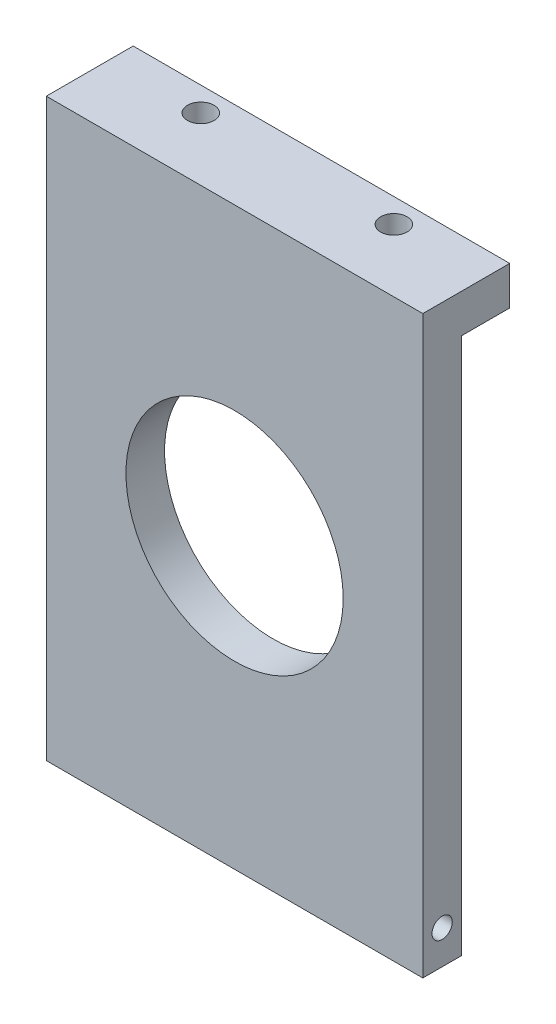
from build123d import *

# Parameters (mm, degrees)
SKETCH_1_W                  = 78
SKETCH_1_H                  = 119.63
SKETCH_1_R                  = 22.5
EXTRUDE_1_DEPTH             = 8
HOLE_WIZARD_M5_1_AT_2_COUNT = 2
HOLE_WIZARD_M5_1_AT_2_PITCH = 58
SKETCH_4_W                  = 78
SKETCH_4_H                  = 23.52391086
EXTRUDE_2_DEPTH             = 8
SKETCH_5_W                  = 78
SKETCH_5_H                  = 8.43
EXTRUDE_3_DEPTH             = 10
SKETCH_6_W                  = 78
SKETCH_6_H                  = 18
CUT_EXTRUDE_1_DEPTH         = 0.43
SKETCH_7_R                  = 2.75
CUT_EXTRUDE_2_DEPTH         = 9
HOLE_WIZARD_M5_2_AT_2_COUNT = 2
HOLE_WIZARD_M5_2_AT_2_PITCH = 90


with BuildPart() as part:
    # 草图1 → 凸台-拉伸1 (new body)
    with BuildSketch(Plane.XY):
        with Locations((-39, 59.815)):
            Rectangle(SKETCH_1_W, SKETCH_1_H)
        with Locations((-39, 59.815)):
            Circle(SKETCH_1_R, mode=Mode.SUBTRACT)
    extrude(amount=EXTRUDE_1_DEPTH)

    # 草图3 → M5 螺纹孔1 (revolve, cut)
    with BuildSketch(Plane(origin=(-68, 119.63, 4), x_dir=(0, 0, 1), z_dir=(1, 0, 0))):
        Polygon((0, 0), (0, 13.6618073), (2.1, 12.4), (2.1, 0), align=None)
    hole_wizard_m5_1 = revolve(axis=Axis((-68, 125.98, 4), (0, -1, 0)), mode=Mode.SUBTRACT)

    # M5 螺纹孔1 at 2: M5 螺纹孔1 ×2
    with Locations(*[(i * HOLE_WIZARD_M5_1_AT_2_PITCH, 0, 0) for i in range(1, HOLE_WIZARD_M5_1_AT_2_COUNT)]):
        add(hole_wizard_m5_1, mode=Mode.SUBTRACT)

    # 镜向1: M5 螺纹孔1 across plane
    add(hole_wizard_m5_1.mirror(Plane.ZX.offset(59.815)), mode=Mode.SUBTRACT)

    # 镜向1 copy 1 sketch → 镜向1 copy 1 (revolve, cut)
    with BuildSketch(Plane(origin=(-10, 0, 4), x_dir=(0, 0, 1), z_dir=(1, 0, 0))):
        Polygon((0, 0), (0, -13.6618073), (2.1, -12.4), (2.1, 0), align=None)
    revolve(axis=Axis((-10, -6.35, 4), (0, -1, 0)), mode=Mode.SUBTRACT)

    # 草图4 → 凸台-拉伸2 (add)
    with BuildSketch(Plane.XY.offset(8)):
        with Locations((-39, 107.86804457)):
            Rectangle(SKETCH_4_W, SKETCH_4_H)
    extrude(amount=-EXTRUDE_2_DEPTH)

    # 草图5 → 凸台-拉伸3 (add)
    with BuildSketch(Plane(origin=(0, 0, 0), x_dir=(-1, 0, 0), z_dir=(0, 0, -1))):
        with Locations((39, 115.415)):
            Rectangle(SKETCH_5_W, SKETCH_5_H)
    extrude(amount=EXTRUDE_3_DEPTH)

    # 草图6 → 切除-拉伸1 (cut)
    with BuildSketch(Plane(origin=(0, 119.63, 0), x_dir=(1, 0, 0), z_dir=(0, 1, 0))):
        with Locations((-39, 1)):
            Rectangle(SKETCH_6_W, SKETCH_6_H)
    extrude(amount=-CUT_EXTRUDE_1_DEPTH, mode=Mode.SUBTRACT)

    # 草图7 → 切除-拉伸2 (cut, through all)
    with BuildSketch(Plane.XZ.offset(-111.2)):
        with Locations((-59, -5)):
            Circle(SKETCH_7_R)
        with Locations((-19, -5)):
            Circle(SKETCH_7_R)
    extrude(amount=-CUT_EXTRUDE_2_DEPTH, mode=Mode.SUBTRACT)

    # 草图9 → M5 螺纹孔2 (revolve, cut)
    with BuildSketch(Plane(origin=(-78, 7, 4), x_dir=(0, 0, 1), z_dir=(0, 1, 0))):
        Polygon((0, 0), (0, 7.2618073), (2.1, 6), (2.1, 0), align=None)
    hole_wizard_m5_2 = revolve(axis=Axis((-84.35, 7, 4), (1, 0, 0)), mode=Mode.SUBTRACT)

    # M5 螺纹孔2 at 2: M5 螺纹孔2 ×2
    with Locations(*[(0, 0, -i * HOLE_WIZARD_M5_2_AT_2_PITCH) for i in range(1, HOLE_WIZARD_M5_2_AT_2_COUNT)]):
        add(hole_wizard_m5_2, mode=Mode.SUBTRACT)

    # 镜向2: M5 螺纹孔2 across plane
    add(hole_wizard_m5_2.mirror(Plane(origin=(-39, 0, 0), x_dir=(0, 0, 1), z_dir=(1, 0, 0))), mode=Mode.SUBTRACT)

    # 镜向2 copy 1 sketch → 镜向2 copy 1 (revolve, cut)
    with BuildSketch(Plane(origin=(0, 7, -86), x_dir=(0, 0, 1), z_dir=(0, 1, 0))):
        Polygon((0, 0), (0, -7.2618073), (2.1, -6), (2.1, 0), align=None)
    revolve(axis=Axis((6.35, 7, -86), (1, 0, 0)), mode=Mode.SUBTRACT)


solid = part.part
